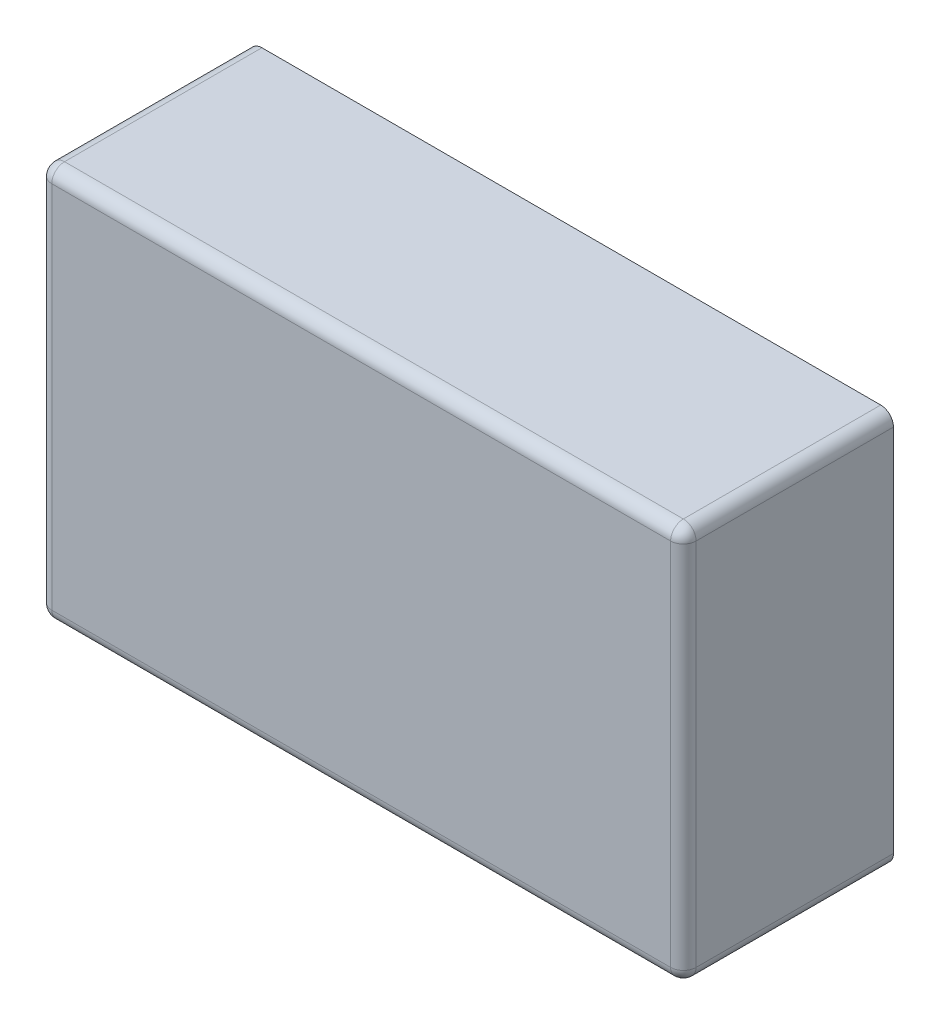
from build123d import *

# Parameters (mm, degrees)
SKETCH1_W           = 253
SKETCH1_H           = 155
BOSS_EXTRUDE1_DEPTH = 82.5
FILLET1_R           = 5
CUT_EXTRUDE1_DEPTH  = 6.3
SKETCH5_W           = 45
SKETCH5_H           = 114
BOSS_EXTRUDE2_DEPTH = 12.7
FILLET2_R           = 3


with BuildPart() as part:
    # Sketch1 → Boss-Extrude1 (new body)
    with BuildSketch(Plane.XY):
        with Locations((126.5, 77.5)):
            Rectangle(SKETCH1_W, SKETCH1_H)
    extrude(amount=BOSS_EXTRUDE1_DEPTH)

    # Fillet1
    fillet1_edges = [part.edges().sort_by_distance(p)[0] for p in [
        (126.5, 155, 82.5),
        (0, 77.5, 82.5),
        (126.5, 0, 82.5),
        (253, 77.5, 82.5),
        (0, 0, 41.25),
        (0, 155, 41.25),
        (253, 155, 41.25),
        (253, 0, 41.25),
    ]]
    fillet(fillet1_edges, radius=FILLET1_R)

    # Sketch2 → Cut-Extrude1 (cut)
    with BuildSketch(Plane(origin=(0, 0, 0), x_dir=(-1, 0, 0), z_dir=(0, 0, -1))):
        with BuildLine():
            Line((-2, 5), (-2, 150))
            ThreePointArc((-2, 150), (-2.878679656, 152.121320344), (-5, 153))
            Line((-5, 153), (-248, 153))
            ThreePointArc((-248, 153), (-250.121320344, 152.121320344), (-251, 150))
            Line((-251, 150), (-251, 5))
            ThreePointArc((-251, 5), (-250.121320344, 2.878679656), (-248, 2))
            Line((-248, 2), (-5, 2))
            ThreePointArc((-5, 2), (-2.878679656, 2.878679656), (-2, 5))
        make_face()
    extrude(amount=-CUT_EXTRUDE1_DEPTH, mode=Mode.SUBTRACT)

    # Sketch5 → Boss-Extrude2 (add)
    with BuildSketch(Plane.ZY):
        with Locations((22.5, 77.5)):
            Rectangle(SKETCH5_W, SKETCH5_H)
    extrude(amount=BOSS_EXTRUDE2_DEPTH)

    # Fillet2
    fillet2_edges = [part.edges().sort_by_distance(p)[0] for p in [
        (-12.7, 134.5, 22.5),
        (-12.7, 20.5, 22.5),
    ]]
    fillet(fillet2_edges, radius=FILLET2_R)


solid = part.part
